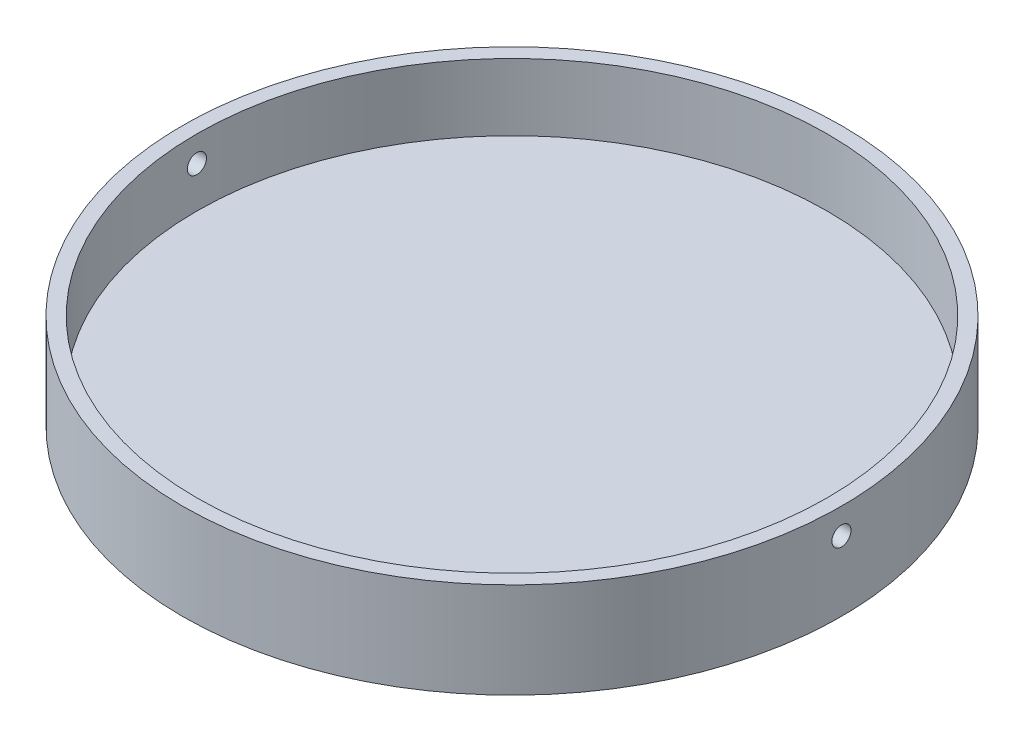
from build123d import *

# Parameters (mm, degrees)
SKETCH1_R               = 34.5
BOSS_EXTRUDE1_DEPTH     = 10
SKETCH2_R               = 33
CUT_EXTRUDE1_DEPTH      = 7
SKETCH3_R               = 1
CUT_EXTRUDE2_DEPTH      = 71.585008529
CUT_EXTRUDE2_DEPTH_BACK = 1


with BuildPart() as part:
    # Sketch1 → Boss-Extrude1 (new body)
    with BuildSketch(Plane(origin=(0, 0, 0), x_dir=(1, 0, 0), z_dir=(0, 1, 0))):
        Circle(SKETCH1_R)
    extrude(amount=BOSS_EXTRUDE1_DEPTH)

    # Sketch2 → Cut-Extrude1 (cut)
    with BuildSketch(Plane(origin=(0, 10, 0), x_dir=(1, 0, 0), z_dir=(0, 1, 0))):
        Circle(SKETCH2_R)
    extrude(amount=-CUT_EXTRUDE1_DEPTH, mode=Mode.SUBTRACT)

    # Sketch3 → Cut-Extrude2 (cut, two sides)
    with BuildSketch(Plane(origin=(-36.085008529, 0, 0), x_dir=(0, 0, -1), z_dir=(1, 0, 0))) as cut_extrude2_sk:
        with Locations((0, 7.3)):
            Circle(SKETCH3_R)
    extrude(amount=CUT_EXTRUDE2_DEPTH, mode=Mode.SUBTRACT)
    extrude(cut_extrude2_sk.sketch, amount=-CUT_EXTRUDE2_DEPTH_BACK, mode=Mode.SUBTRACT)


solid = part.part
